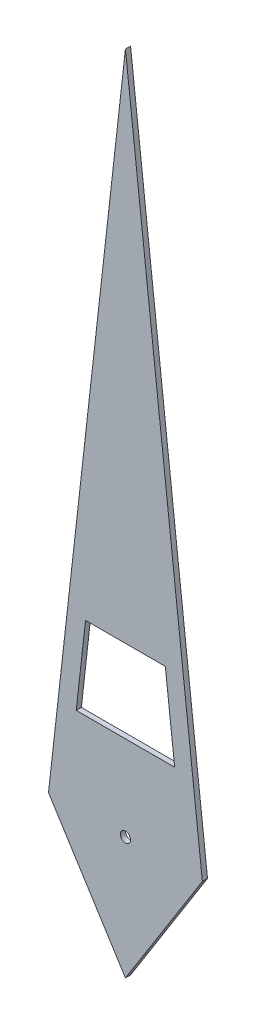
from build123d import *

# Parameters (mm, degrees)
SKETCH1_R           = 0.1
BOSS_EXTRUDE1_DEPTH = 0.1
CUT_EXTRUDE1_DEPTH  = 0.1


with BuildPart() as part:
    # Sketch1 → Boss-Extrude1 (new body)
    with BuildSketch(Plane.XY):
        Polygon((0, 13.302859744), (1.5, 0), (0, -2.380255614), (-1.5, 0), align=None)
        Circle(SKETCH1_R, mode=Mode.SUBTRACT)
    extrude(amount=BOSS_EXTRUDE1_DEPTH)

    # Sketch2 → Cut-Extrude1 (cut)
    with BuildSketch(Plane.XY.offset(0.1)):
        Polygon((-0.959190931, 1.658080162), (0.959190931, 1.658080162), (0.777629766, 3.268268638), (-0.777629766, 3.268268638), align=None)
    extrude(amount=-CUT_EXTRUDE1_DEPTH, mode=Mode.SUBTRACT)


solid = part.part
